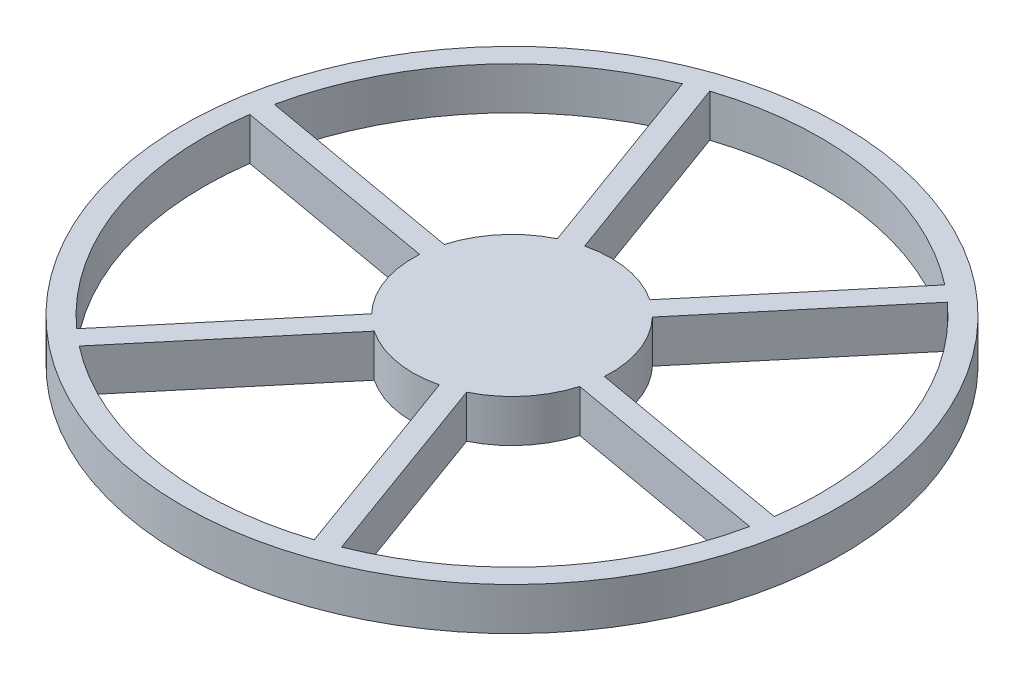
from build123d import *

# Parameters (mm, degrees)
SKETCH1_R           = 98.425
BOSS_EXTRUDE1_DEPTH = 12.7
CUT_EXTRUDE1_DEPTH  = 13.7


with BuildPart() as part:
    # Sketch1 → Boss-Extrude1 (new body)
    with BuildSketch(Plane(origin=(0, 0, 0), x_dir=(1, 0, 0), z_dir=(0, 1, 0))):
        Circle(SKETCH1_R)
    extrude(amount=BOSS_EXTRUDE1_DEPTH)

    # Sketch2 → Cut-Extrude1 (cut, through all)
    with BuildSketch(Plane(origin=(0, 12.7, 0), x_dir=(1, 0, 0), z_dir=(0, 1, 0))):
        with BuildLine():
            Line((21.383254088, 20.544146731), (61.581662722, 68.450744637))
            ThreePointArc((61.581662722, 68.450744637), (86.522198059, 31.491504697), (91.173581053, -12.852382775))
            Line((91.173581053, -12.852382775), (29.586045941, -1.992838659))
            ThreePointArc((29.586045941, -1.992838659), (27.864786272, 10.141952787), (21.383254088, 20.544146731))
        make_face()
        with BuildLine():
            Line((16.518871875, 24.625848052), (56.717280509, 72.532445958))
            ThreePointArc((56.717280509, 72.532445958), (15.988655959, 90.676173859), (-28.489252402, 87.556656643))
            Line((-28.489252402, 87.556656643), (-7.100125924, 28.790514622))
            ThreePointArc((-7.100125924, 28.790514622), (5.149204378, 29.202589176), (16.518871875, 24.625848052))
        make_face()
        with BuildLine():
            Line((-13.067174066, 26.618686712), (-34.456300544, 85.384828733))
            ThreePointArc((-34.456300544, 85.384828733), (-70.5335421, 59.184669162), (-90.070915125, 19.105912006))
            Line((-90.070915125, 19.105912006), (-28.483380012, 8.246367891))
            ThreePointArc((-28.483380012, 8.246367891), (-22.715581894, 19.060636389), (-13.067174066, 26.618686712))
        make_face()
        with BuildLine():
            Line((-29.586045941, 1.992838659), (-91.173581053, 12.852382775))
            ThreePointArc((-91.173581053, 12.852382775), (-86.522198059, -31.491504697), (-61.581662722, -68.450744637))
            Line((-61.581662722, -68.450744637), (-21.383254088, -20.544146731))
            ThreePointArc((-21.383254088, -20.544146731), (-27.864786272, -10.141952787), (-29.586045941, 1.992838659))
        make_face()
        with BuildLine():
            Line((-16.518871875, -24.625848052), (-56.717280509, -72.532445958))
            ThreePointArc((-56.717280509, -72.532445958), (-15.988655959, -90.676173859), (28.489252402, -87.556656643))
            Line((28.489252402, -87.556656643), (7.100125924, -28.790514622))
            ThreePointArc((7.100125924, -28.790514622), (-5.149204378, -29.202589176), (-16.518871875, -24.625848052))
        make_face()
        with BuildLine():
            Line((13.067174066, -26.618686712), (34.456300544, -85.384828733))
            ThreePointArc((34.456300544, -85.384828733), (70.5335421, -59.184669162), (90.070915125, -19.105912006))
            Line((90.070915125, -19.105912006), (28.483380012, -8.246367891))
            ThreePointArc((28.483380012, -8.246367891), (22.715581894, -19.060636389), (13.067174066, -26.618686712))
        make_face()
    extrude(amount=-CUT_EXTRUDE1_DEPTH, mode=Mode.SUBTRACT)


solid = part.part
